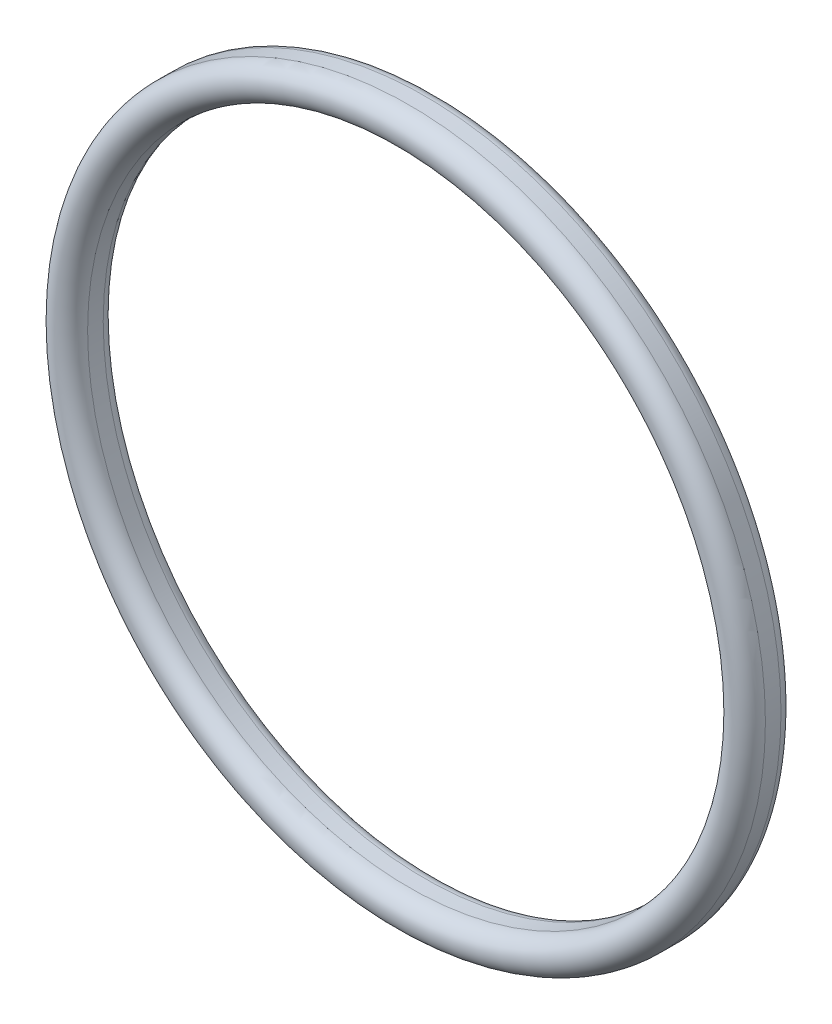
from build123d import *


with BuildPart() as part:
    # Sketch1 → Revolve1 (revolve)
    with BuildSketch(Plane(origin=(0, 0, 0), x_dir=(0, 0, -1), z_dir=(1, 0, 0))):
        with BuildLine():
            Line((-2.314, 27.1), (-1, 27.1))
            ThreePointArc((-1, 27.1), (-0.292893219, 27.392893219), (0, 28.1))
            Line((0, 28.1), (0, 29))
            ThreePointArc((0, 29), (-0.292893219, 29.707106781), (-1, 30))
            Line((-1, 30), (-2.314, 30))
            ThreePointArc((-2.314, 30), (-3.764, 28.55), (-2.314, 27.1))
        make_face()
    revolve(axis=Axis((0, 0, 0), (0, 0, 1)))


solid = part.part
